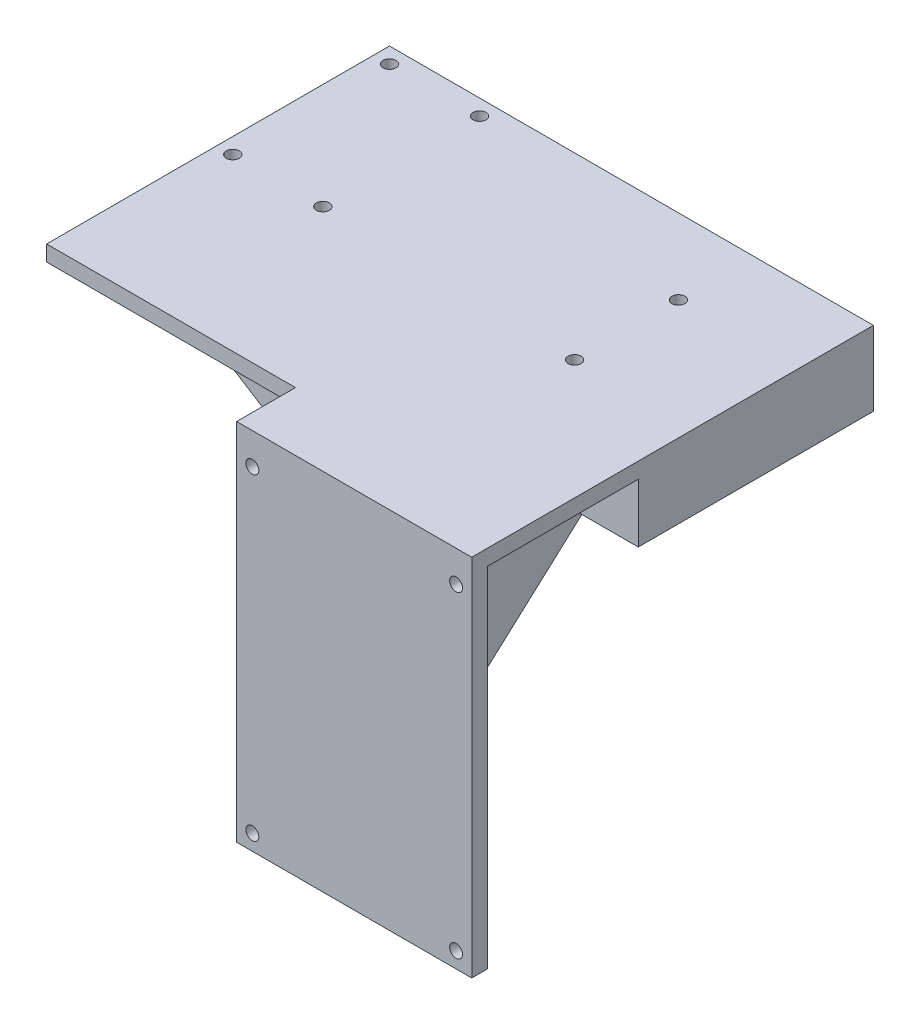
from build123d import *

# Parameters (mm, degrees)
SKETCH1_W           = 60
SKETCH1_H           = 93
BOSS_EXTRUDE1_DEPTH = 4
SKETCH3_R           = 1.65
CUT_EXTRUDE1_DEPTH  = 4
SKETCH5_W           = 60
SKETCH5_H           = 4
BOSS_EXTRUDE2_DEPTH = 11
SKETCH6_W           = 123.5
SKETCH6_H           = 4
BOSS_EXTRUDE3_DEPTH = 87.5
SKETCH7_R           = 1.65
CUT_EXTRUDE2_DEPTH  = 87.5
SKETCH10_R          = 1.65
CUT_EXTRUDE3_DEPTH  = 10
SKETCH11_W          = 98.5
SKETCH11_H          = 89
BOSS_EXTRUDE4_DEPTH = 25
SKETCH13_W          = 98.5
SKETCH13_H          = 89
CUT_EXTRUDE5_DEPTH  = 8
CUT_EXTRUDE7_DEPTH  = 20
SKETCH15_W          = 71.5
SKETCH15_H          = 17
BOSS_EXTRUDE6_DEPTH = 45
CUT_EXTRUDE9_DEPTH  = 45
SKETCH17_W          = 25
SKETCH17_H          = 60
BOSS_EXTRUDE7_DEPTH = 15


with BuildPart() as part:
    # Sketch1 → Boss-Extrude1 (new body)
    with BuildSketch(Plane.XY):
        with Locations((30, -46.5)):
            Rectangle(SKETCH1_W, SKETCH1_H)
    extrude(amount=-BOSS_EXTRUDE1_DEPTH)

    # Sketch3 → Cut-Extrude1 (cut)
    with BuildSketch(Plane.XY):
        with Locations((4, -8)):
            Circle(SKETCH3_R)
        with Locations((56, -8)):
            Circle(SKETCH3_R)
        with Locations((4, -89)):
            Circle(SKETCH3_R)
        with Locations((56, -89)):
            Circle(SKETCH3_R)
    extrude(amount=-CUT_EXTRUDE1_DEPTH, mode=Mode.SUBTRACT)

    # Sketch5 → Boss-Extrude2 (add)
    with BuildSketch(Plane(origin=(0, 0, -4), x_dir=(-1, 0, 0), z_dir=(0, 0, -1))):
        with Locations((-30, -2)):
            Rectangle(SKETCH5_W, SKETCH5_H)
    extrude(amount=BOSS_EXTRUDE2_DEPTH)

    # Sketch6 → Boss-Extrude3 (add)
    with BuildSketch(Plane(origin=(0, 0, -15), x_dir=(-1, 0, 0), z_dir=(0, 0, -1))):
        with Locations((1.75, -2)):
            Rectangle(SKETCH6_W, SKETCH6_H)
    extrude(amount=BOSS_EXTRUDE3_DEPTH)

    # Sketch7 → Cut-Extrude2 (cut)
    with BuildSketch(Plane(origin=(0, 0, 0), x_dir=(1, 0, 0), z_dir=(0, 1, 0))):
        with Locations((-59.5, 98.5)):
            Circle(SKETCH7_R)
        with Locations((-36.5, 98.5)):
            Circle(SKETCH7_R)
        with Locations((-59.5, 58.5)):
            Circle(SKETCH7_R)
        with Locations((-36.5, 58.5)):
            Circle(SKETCH7_R)
    extrude(amount=-CUT_EXTRUDE2_DEPTH, mode=Mode.SUBTRACT)

    # Sketch10 → Cut-Extrude3 (cut)
    with BuildSketch(Plane(origin=(0, 0, 0), x_dir=(1, 0, 0), z_dir=(0, 1, 0))):
        with Locations((29.5, 83.25)):
            Circle(SKETCH10_R)
        with Locations((29.5, 56.75)):
            Circle(SKETCH10_R)
    extrude(amount=-CUT_EXTRUDE3_DEPTH, mode=Mode.SUBTRACT)

    # Sketch11 → Boss-Extrude4 (add)
    with BuildSketch(Plane(origin=(0, 0, 0), x_dir=(0, 0, -1), z_dir=(1, 0, 0))):
        with Locations((53.25, -48.5)):
            Rectangle(SKETCH11_W, SKETCH11_H)
    extrude(amount=BOSS_EXTRUDE4_DEPTH)

    # Sketch13 → Cut-Extrude5 (cut)
    with BuildSketch(Plane.ZY):
        with Locations((-53.25, -48.5)):
            Rectangle(SKETCH13_W, SKETCH13_H)
    extrude(amount=-CUT_EXTRUDE5_DEPTH, mode=Mode.SUBTRACT)

    # Sketch14 → Cut-Extrude7 (cut)
    with BuildSketch(Plane.ZY.offset(-8)):
        Polygon((-102.5, -4), (-102.5, -93), (-4, -93), align=None)
    extrude(amount=-CUT_EXTRUDE7_DEPTH, mode=Mode.SUBTRACT)

    # Sketch15 → Boss-Extrude6 (add)
    with BuildSketch(Plane.XZ.offset(4)):
        with Locations((-27.75, -42)):
            Rectangle(SKETCH15_W, SKETCH15_H)
    extrude(amount=BOSS_EXTRUDE6_DEPTH)

    # Sketch16 → Cut-Extrude9 (cut)
    with BuildSketch(Plane(origin=(0, 0, -50.5), x_dir=(-1, 0, 0), z_dir=(0, 0, -1))):
        Polygon((63.5, -4), (-8, -49), (63.5, -49), align=None)
    extrude(amount=-CUT_EXTRUDE9_DEPTH, mode=Mode.SUBTRACT)

    # Sketch17 → Boss-Extrude7 (add)
    with BuildSketch(Plane.XZ.offset(4)):
        with Locations((47.5, -72.5)):
            Rectangle(SKETCH17_W, SKETCH17_H)
    extrude(amount=BOSS_EXTRUDE7_DEPTH)


solid = part.part
